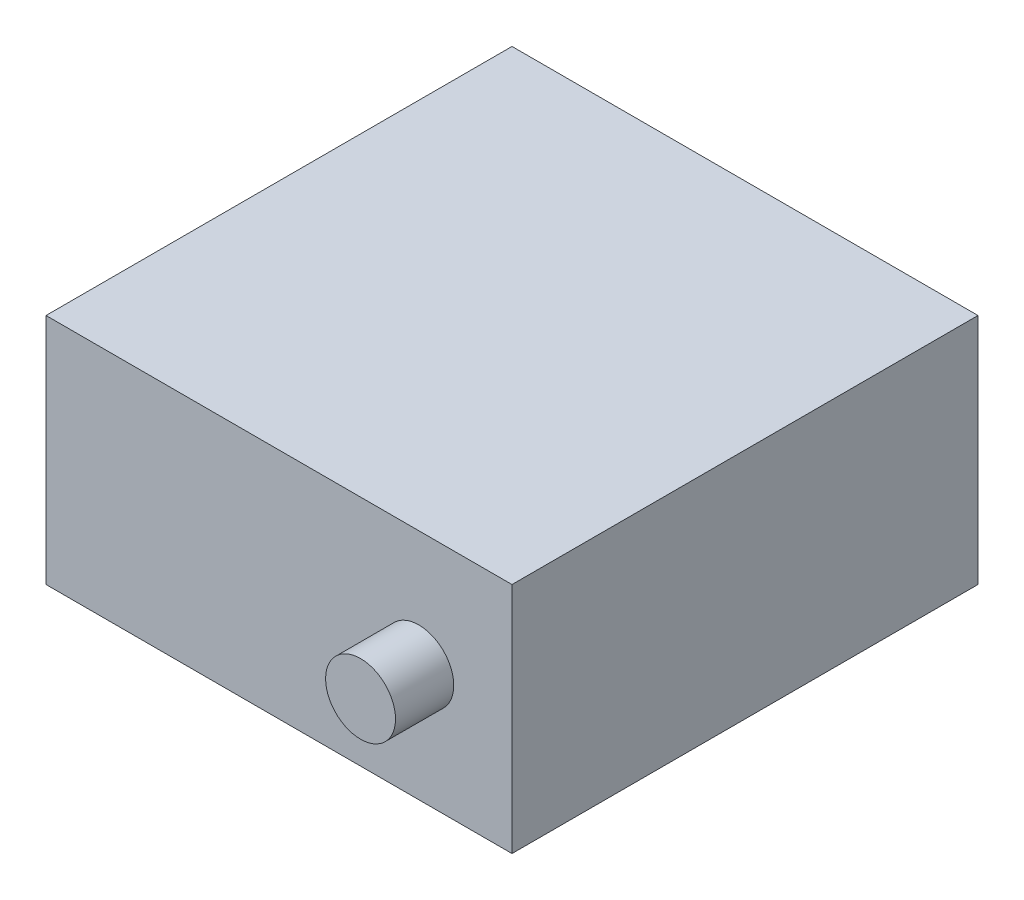
from build123d import *

# Parameters (mm, degrees)
SKETCH_1_W      = 40
SKETCH_1_H      = 40
EXTRUDE_1_DEPTH = 20
SKETCH_2_R      = 3
EXTRUDE_2_DEPTH = 5


with BuildPart() as part:
    # 草图1 → 凸台-拉伸1 (new body)
    with BuildSketch(Plane(origin=(0, 0, 0), x_dir=(1, 0, 0), z_dir=(0, 1, 0))):
        Rectangle(SKETCH_1_W, SKETCH_1_H)
    extrude(amount=EXTRUDE_1_DEPTH)

    # 草图2 → 凸台-拉伸2 (add)
    with BuildSketch(Plane.XY.offset(20)):
        with Locations((12, 10)):
            Circle(SKETCH_2_R)
    extrude(amount=EXTRUDE_2_DEPTH)


solid = part.part
